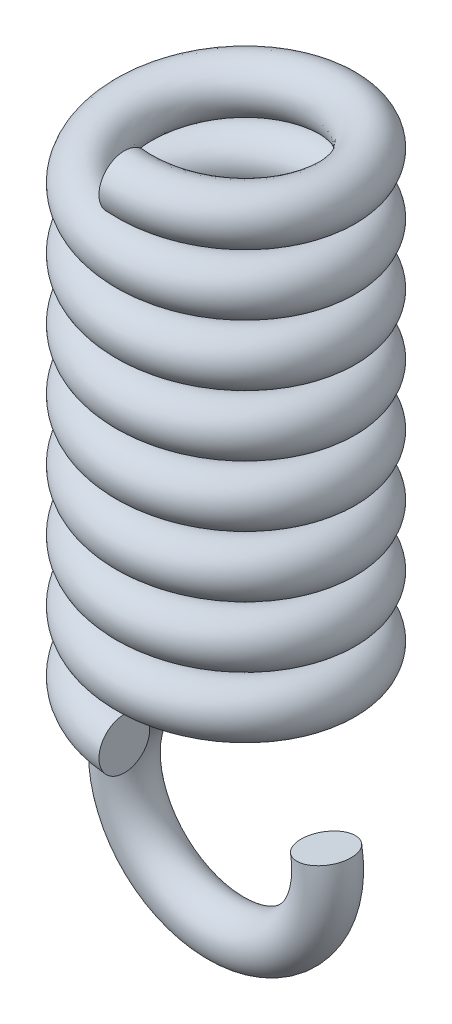
from build123d import *

# Parameters (mm, degrees)
SWEEP_1_PITCH  = 6
SWEEP_1_HEIGHT = 48
SWEEP_1_RADIUS = 10
SKETCH_1_R     = 2.5
SKETCH_5_R     = 2.5


with BuildPart() as part:
    # 扫描1: sweep along a helix
    with BuildLine() as sweep_1_path:
        Helix(SWEEP_1_PITCH, SWEEP_1_HEIGHT, SWEEP_1_RADIUS, center=(0, 0, 0), direction=(0, 1, 0), lefthand=True)
    # 草图1 → 扫描1 (sweep)
    with BuildSketch(Plane.XY):
        with Locations((10, 0)):
            Circle(SKETCH_1_R)
    sweep(path=sweep_1_path.line, is_frenet=True)


with BuildPart() as body_2:
    # 扫描2: sweep along a path in 草图6
    with BuildLine(Plane.XY) as sweep_2_path:
        ThreePointArc((0, -5.243336651), (-6.427876097, -22.903781082), (9.84807753, -13.506854874))
    # 草图5 → 扫描2 (sweep)
    with BuildSketch(Plane(origin=(0, 0, 0), x_dir=(0, 0, -1), z_dir=(1, 0, 0))):
        with Locations((0, -5.243336651)):
            Circle(SKETCH_5_R)
    sweep(path=sweep_2_path.line)


solid = Compound([part.part, body_2.part])
